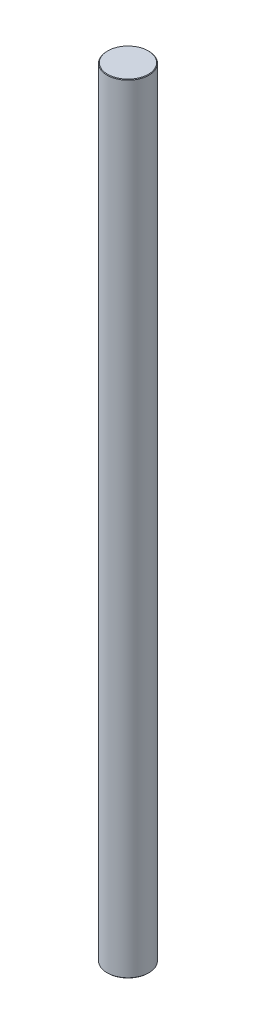
from build123d import *

# Parameters (mm, degrees)
SKETCH1_R           = 4.7625
BOSS_EXTRUDE1_DEPTH = 177.8
CHAMFER1_SIZE       = 0.127


with BuildPart() as part:
    # Sketch1 → Boss-Extrude1 (new body)
    with BuildSketch(Plane(origin=(0, 0, 0), x_dir=(1, 0, 0), z_dir=(0, 1, 0))):
        Circle(SKETCH1_R)
    extrude(amount=BOSS_EXTRUDE1_DEPTH)

    # Chamfer1
    chamfer1_edges = [part.edges().sort_by_distance(p)[0] for p in [
        (-4.7625, 0, 0),
        (-4.7625, 177.8, 0),
    ]]
    chamfer(chamfer1_edges, length=CHAMFER1_SIZE)


solid = part.part
